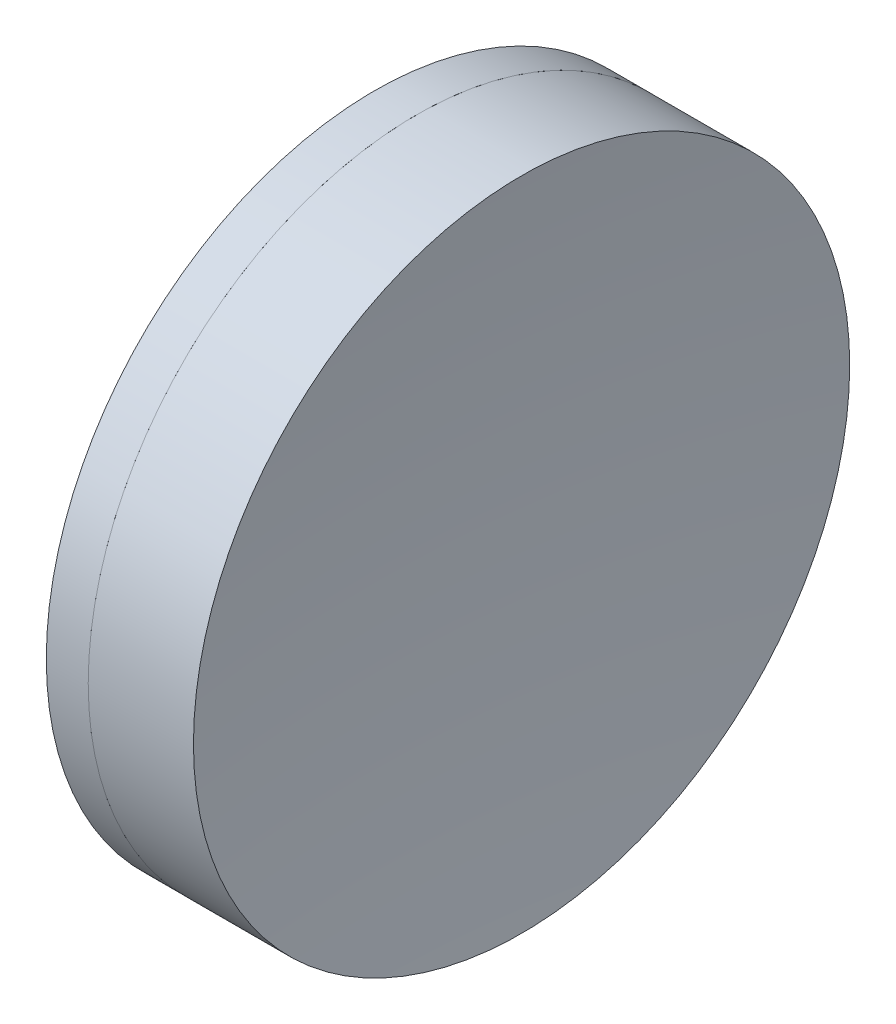
from build123d import *


with BuildPart() as part:
    # 草图1 one side → 旋转1 (revolve)
    with BuildSketch(Plane(origin=(0, 0, 0), x_dir=(1, 0, 0), z_dir=(0, 1, 0)), mode=Mode.PRIVATE) as revolve_1_sk:
        with BuildLine():
            ThreePointArc((141.919467113, 25.4), (138.18875984, 12.942761808), (136.929443783, 0))
            Line((136.929443783, 0), (148.929443783, 0))
            ThreePointArc((148.929443783, 0), (147.983180973, 12.838732616), (145.164842773, 25.4))
            Line((145.164842773, 25.4), (141.919467113, 25.4))
        make_face()
    revolve(revolve_1_sk.sketch.rotate(Axis((-0.816062176, 0, 0), (1, 0, 0)), 180), axis=Axis((-0.816062176, 0, 0), (1, 0, 0)))  # turned: the seam where the file's is


with BuildPart() as body_2:
    # 草图2 one side → 旋转2 (revolve)
    with BuildSketch(Plane(origin=(0, 0, 0), x_dir=(1, 0, 0), z_dir=(0, 1, 0)), mode=Mode.PRIVATE) as revolve_2_sk:
        with BuildLine():
            Line((153.310472597, 25.4), (145.164842773, 25.4))
            ThreePointArc((145.164842773, 25.4), (147.983180973, 12.838732616), (148.929443783, 0))
            Line((148.929443783, 0), (151.929443783, 0))
            ThreePointArc((151.929443783, 0), (152.274955774, 12.7187582), (153.310472597, 25.4))
        make_face()
    revolve(revolve_2_sk.sketch.rotate(Axis((-0.551919993, 0, 0), (1, 0, 0)), 180), axis=Axis((-0.551919993, 0, 0), (1, 0, 0)))  # turned: the seam where the file's is


solid = Compound([part.part, body_2.part])
